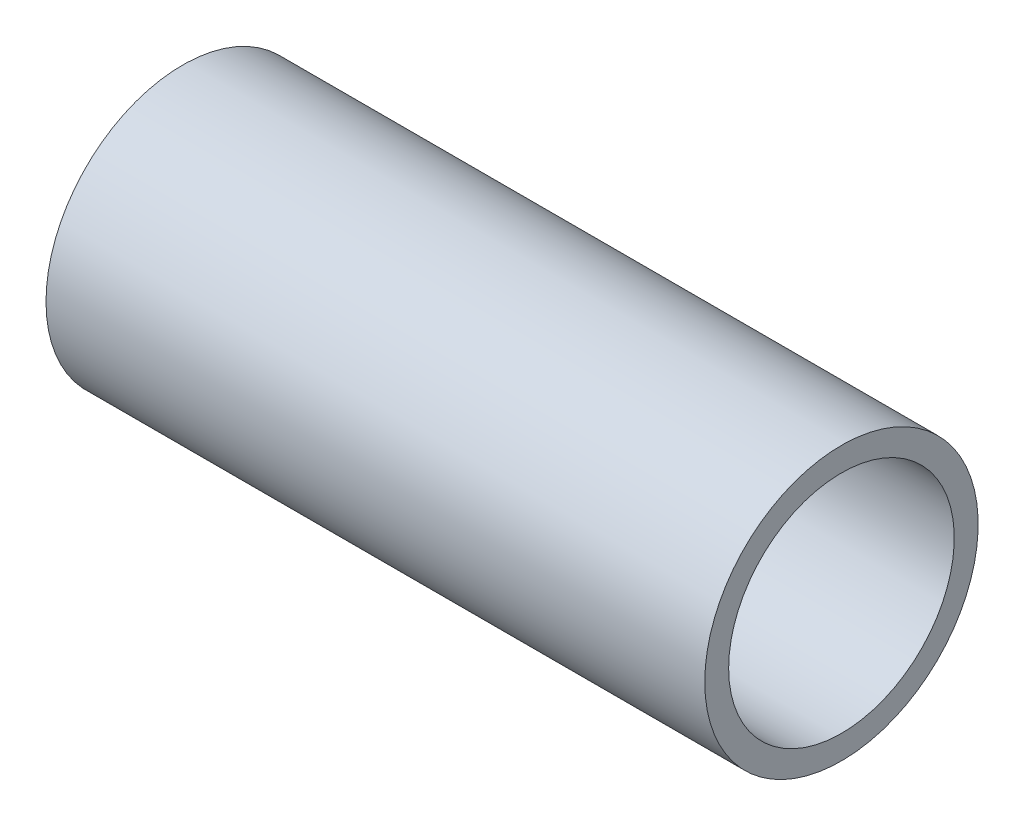
from build123d import *

# Parameters (mm, degrees)
SKETCH1_W = 101.6
SKETCH1_H = 3.683


with BuildPart() as part:
    # Sketch1 → Revolve1 (revolve)
    with BuildSketch(Plane.XY):
        with Locations((50.8, 19.2405)):
            Rectangle(SKETCH1_W, SKETCH1_H)
    revolve(axis=Axis((-19.56978903, 0, 0), (1, 0, 0)))


solid = part.part
